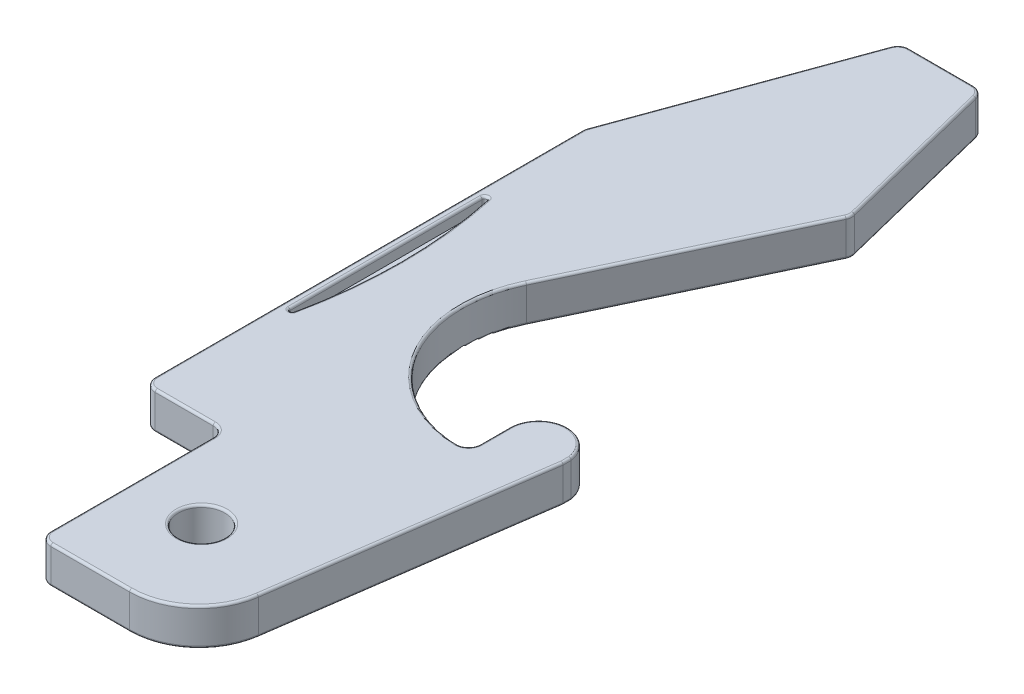
from build123d import *

# Parameters (mm, degrees)
BOSS_EXTRUDE1_DEPTH = 1.6
FILLET1_R           = 3
SKETCH2_R           = 1
SKETCH2_W           = 3.5
SKETCH2_H           = 8
CUT_EXTRUDE3_DEPTH  = 2.6
FILLET2_R           = 0.5
FILLET4_R           = 0.1
FILLET5_R           = 0.1
CUT_EXTRUDE6_DEPTH  = 0.5
FILLET7_R           = 0.1
FILLET8_R           = 0.1
FILLET9_R           = 0.1


with BuildPart() as part:
    # Sketch1 → Boss-Extrude1 (new body)
    with BuildSketch(Plane(origin=(0, 0, 0), x_dir=(1, 0, 0), z_dir=(0, 1, 0))):
        with BuildLine():
            Line((-21.61236181, -22.431846947), (-21.61236181, -49.431846947))
            Line((-21.61236181, -49.431846947), (-11.61236181, -49.431846947))
            Line((-11.61236181, -49.431846947), (-9.61236181, -35.357710944))
            Line((-9.61236181, -35.357710944), (-9.61236181, -35.005982949))
            ThreePointArc((-9.61236181, -35.005982949), (-10.93808019, -33.934959093), (-12.099928719, -35.181846947))
            Line((-12.099928719, -35.181846947), (-12.099928719, -36.938283631))
            ThreePointArc((-12.099928719, -36.938283631), (-16.735929752, -34.607077277), (-17.115428983, -29.431846947))
            Line((-17.115428983, -29.431846947), (-12.61236181, -19.931846947))
            Line((-12.61236181, -19.931846947), (-14.474400667, -12.431846947))
            Line((-14.474400667, -12.431846947), (-17.974400667, -12.431846947))
            Line((-17.974400667, -12.431846947), (-21.61236181, -22.431846947))
        make_face()
    extrude(amount=BOSS_EXTRUDE1_DEPTH)

    # Fillet1
    fillet1_edges = [part.edges().sort_by_distance(p)[0] for p in [
        (-11.61236181, 0.8, 49.431846947),
    ]]
    fillet(fillet1_edges, radius=FILLET1_R)

    # Sketch2 → Cut-Extrude3 (cut, through all)
    with BuildSketch(Plane(origin=(0, 0, 0), x_dir=(1, 0, 0), z_dir=(0, 1, 0))):
        with Locations((-15.11236181, -45.431846947)):
            Circle(SKETCH2_R)
        with Locations((-19.86236181, -45.431846947)):
            Rectangle(SKETCH2_W, SKETCH2_H)
    extrude(amount=CUT_EXTRUDE3_DEPTH, mode=Mode.SUBTRACT)

    # Fillet2
    fillet2_edges = [part.edges().sort_by_distance(p)[0] for p in [
        (-21.61236181, 0.8, 22.431846947),
        (-17.974400667, 0.8, 12.431846947),
        (-14.474400667, 0.8, 12.431846947),
        (-12.61236181, 0.8, 19.931846947),
        (-12.099928719, 0.8, 36.938283631),
        (-21.61236181, 0.8, 41.431846947),
        (-18.11236181, 0.8, 49.431846947),
        (-18.11236181, 0.8, 41.431846947),
    ]]
    fillet(fillet2_edges, radius=FILLET2_R)

    # Fillet4
    fillet4_edges = [part.edges().sort_by_distance(p)[0] for p in [
        (-9.61236181, 0, 35.181846947),
        (-10.429194161, 0, 41.105815742),
        (-16.876302836, 0, 34.385192966),
        (-10.93808019, 0, 33.934959093),
        (-12.249746245, 0, 48.697483809),
        (-16.11236181, 0, 45.431846947),
        (-12.099928719, 0, 35.81037464),
        (-13.517780977, 0, 16.284960777),
        (-18.11236181, 0, 45.431846947),
        (-19.86236181, 0, 41.431846947),
        (-21.61236181, 0, 31.725908874),
        (-19.838173309, 0, 17.554971048),
        (-16.244841834, 0, 12.431846947),
        (-14.902135134, 0, 24.762520295),
        (-15.914274452, 0, 49.431846947),
        (-17.965915201, 0, 49.285400337),
        (-21.465915201, 0, 41.285400337),
        (-21.60477236, 0, 22.43318457),
        (-17.911059314, 0, 12.522292974),
        (-14.557417423, 0, 12.537994701),
        (-12.643133893, 0, 19.92877053),
        (-12.255310999, 0, 36.801171056),
        (-18.258808419, 0, 41.578293556),
    ]]
    fillet(fillet4_edges, radius=FILLET4_R)

    # Fillet5
    fillet5_edges = [part.edges().sort_by_distance(p)[0] for p in [
        (-16.876302836, 1.6, 34.385192966),
        (-12.249746245, 1.6, 48.697483809),
        (-10.429194161, 1.6, 41.105815742),
        (-9.61236181, 1.6, 35.181846947),
        (-10.93808019, 1.6, 33.934959093),
        (-16.11236181, 1.6, 45.431846947),
        (-12.099928719, 1.6, 35.81037464),
        (-13.517780977, 1.6, 16.284960777),
        (-14.902135134, 1.6, 24.762520295),
        (-19.86236181, 1.6, 41.431846947),
        (-18.11236181, 1.6, 45.431846947),
        (-15.914274452, 1.6, 49.431846947),
        (-16.244841834, 1.6, 12.431846947),
        (-19.838173309, 1.6, 17.554971048),
        (-21.61236181, 1.6, 31.725908874),
        (-17.965915201, 1.6, 49.285400337),
        (-21.465915201, 1.6, 41.285400337),
        (-21.60477236, 1.6, 22.43318457),
        (-17.911059314, 1.6, 12.522292974),
        (-14.557417423, 1.6, 12.537994701),
        (-12.643133893, 1.6, 19.92877053),
        (-12.255310999, 1.6, 36.801171056),
        (-18.258808419, 1.6, 41.578293556),
    ]]
    fillet(fillet5_edges, radius=FILLET5_R)

    # Sketch4 → Cut-Extrude6 (cut)
    with BuildSketch(Plane(origin=(0, 1.6, 0), x_dir=(1, 0, 0), z_dir=(0, 1, 0))):
        with BuildLine():
            Line((-21.26236181, -26.331846947), (-21.26236181, -36.331846947))
            ThreePointArc((-21.26236181, -36.331846947), (-20.627278541, -31.331846947), (-21.26236181, -26.331846947))
        make_face()
    extrude(amount=-CUT_EXTRUDE6_DEPTH, mode=Mode.SUBTRACT)

    # Fillet7
    fillet7_edges = [part.edges().sort_by_distance(p)[0] for p in [
        (-21.26236181, 1.35, 36.331846947),
    ]]
    fillet(fillet7_edges, radius=FILLET7_R)

    # Fillet8
    fillet8_edges = [part.edges().sort_by_distance(p)[0] for p in [
        (-21.26236181, 1.35, 26.331846947),
    ]]
    fillet(fillet8_edges, radius=FILLET8_R)

    # Fillet9
    fillet9_edges = [part.edges().sort_by_distance(p)[0] for p in [
        (-20.627278541, 1.6, 31.331846947),
        (-21.172817306, 1.6, 35.569778851),
        (-21.26236181, 1.6, 31.331846947),
        (-21.172817306, 1.6, 27.093915042),
    ]]
    fillet(fillet9_edges, radius=FILLET9_R)


solid = part.part
